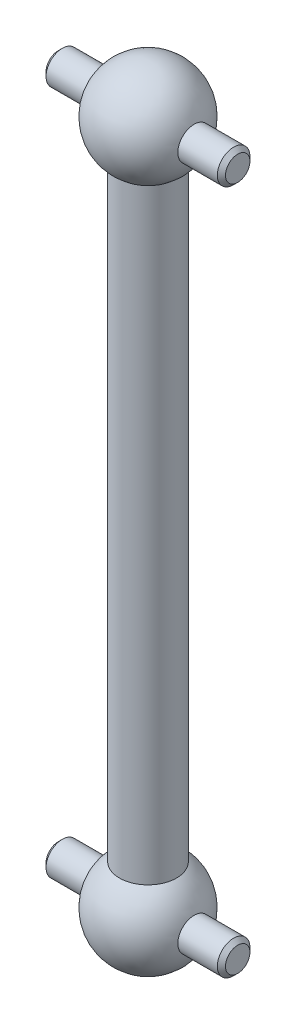
from build123d import *

# Parameters (mm, degrees)
ESQUISSE3_R        = 1
BOSS_EXTRU_1_DEPTH = 5.5
CHANFREIN1_SIZE    = 0.25


with BuildPart() as part:
    # Esquisse1 → Base-Révolution (revolve)
    with BuildSketch(Plane.XY):
        with BuildLine():
            Line((1.75, 39.563301414), (1.75, 2.436698586))
            ThreePointArc((1.75, 2.436698586), (2.855704445, -0.919212772), (0, -3))
            Line((0, -3), (0, 45))
            ThreePointArc((0, 45), (2.855704445, 42.919212772), (1.75, 39.563301414))
        make_face()
    revolve(axis=Axis((0, -3, 0), (0, 1, 0)))

    # Esquisse3 → Boss.-Extru.1 (add, symmetric)
    with BuildSketch(Plane(origin=(0, 0, 0), x_dir=(0, 0, -1), z_dir=(1, 0, 0))):
        Circle(ESQUISSE3_R)
        with Locations((0, 42)):
            Circle(ESQUISSE3_R)
    extrude(amount=BOSS_EXTRU_1_DEPTH, both=True)

    # Chanfrein1
    chanfrein1_edges = [part.edges().sort_by_distance(p)[0] for p in [
        (5.5, 42, 1),
        (-5.5, 42, 1),
        (5.5, 0, 1),
        (-5.5, 0, 1),
    ]]
    chamfer(chanfrein1_edges, length=CHANFREIN1_SIZE)


solid = part.part
